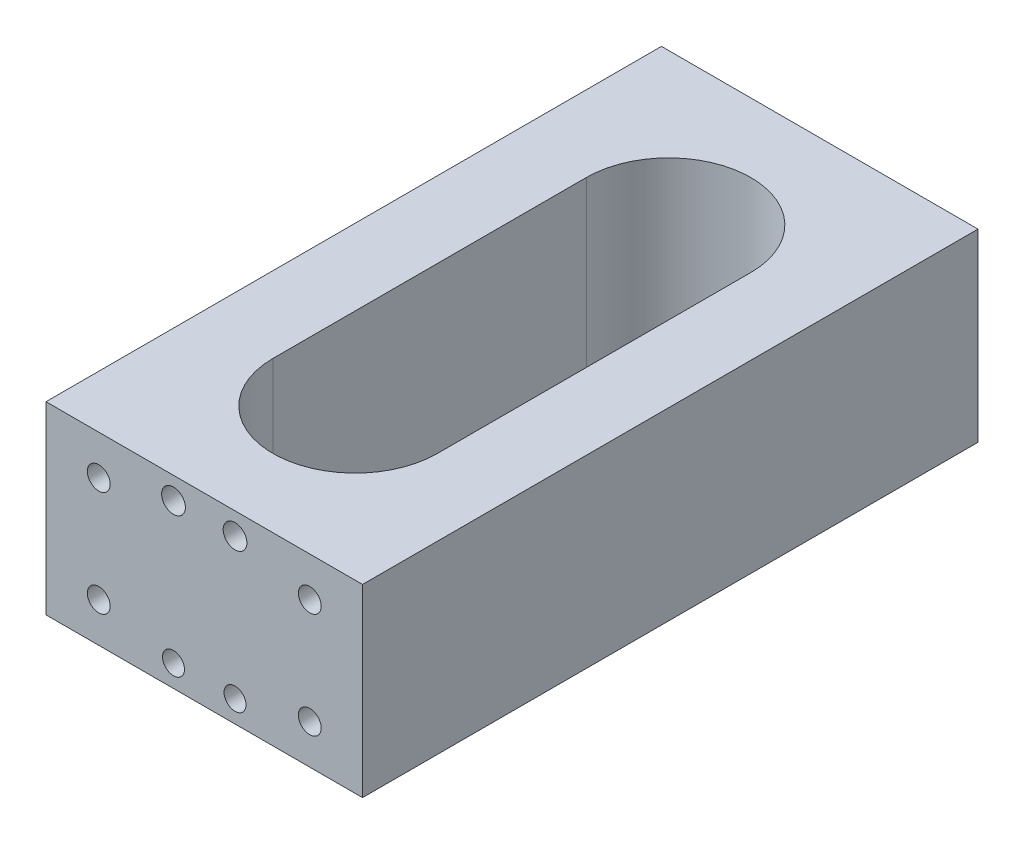
from build123d import *

# Parameters (mm, degrees)
SKETCH_1_W          = 36
SKETCH_1_H          = 21
SKETCH_1_R          = 1.25
SKETCH_1_R_2        = 1.3
SKETCH_1_R_3        = 1.35
EXTRUDE_1_DEPTH     = 70
SKETCH_1_5_R        = 1.3
SKETCH_1_5_R_2      = 1.35
SKETCH_1_5_R_3      = 1.25
CUT_EXTRUDE_1_DEPTH = 4
CUT_EXTRUDE_START   = 70
SKETCH_1_6_R        = 1.35
SKETCH_1_6_R_2      = 1.3
SKETCH_1_6_R_3      = 1.25
CUT_EXTRUDE_2_DEPTH = 4
CUT_EXTRUDE1_DEPTH  = 30


with BuildPart() as part:
    # 스케치1 → 보스-돌출1 (new body)
    with BuildSketch(Plane.XY):
        Rectangle(SKETCH_1_W, SKETCH_1_H)
        with Locations((-3.5, -8)):
            Circle(SKETCH_1_R, mode=Mode.SUBTRACT)
        with Locations((3.5, -8)):
            Circle(SKETCH_1_R, mode=Mode.SUBTRACT)
        with Locations((-12, 6)):
            Circle(SKETCH_1_R_2, mode=Mode.SUBTRACT)
        with Locations((12, 6)):
            Circle(SKETCH_1_R_2, mode=Mode.SUBTRACT)
        with Locations((12, -6)):
            Circle(SKETCH_1_R_2, mode=Mode.SUBTRACT)
        with Locations((-12, -6)):
            Circle(SKETCH_1_R_2, mode=Mode.SUBTRACT)
        with Locations((3.5, 8)):
            Circle(SKETCH_1_R_3, mode=Mode.SUBTRACT)
        with Locations((-3.5, 8)):
            Circle(SKETCH_1_R_3, mode=Mode.SUBTRACT)
        with Locations((12, -6)):
            Circle(SKETCH_1_R_2)
        with Locations((3.5, -8)):
            Circle(SKETCH_1_R)
        with Locations((-3.5, -8)):
            Circle(SKETCH_1_R)
        with Locations((-12, -6)):
            Circle(SKETCH_1_R_2)
        with Locations((-12, 6)):
            Circle(SKETCH_1_R_2)
        with Locations((-3.5, 8)):
            Circle(SKETCH_1_R_3)
        with Locations((3.5, 8)):
            Circle(SKETCH_1_R_3)
        with Locations((12, 6)):
            Circle(SKETCH_1_R_2)
    extrude(amount=EXTRUDE_1_DEPTH)

    # 스케치1<5> → 컷-돌출1 (cut)
    with BuildSketch(Plane.XY):
        with Locations((12, 6)):
            Circle(SKETCH_1_5_R)
        with Locations((3.5, 8)):
            Circle(SKETCH_1_5_R_2)
        with Locations((-3.5, 8)):
            Circle(SKETCH_1_5_R_2)
        with Locations((-12, 6)):
            Circle(SKETCH_1_5_R)
        with Locations((-12, -6)):
            Circle(SKETCH_1_5_R)
        with Locations(Location((-3.5, -8, 0), (0, 0, 180))):
            Circle(SKETCH_1_5_R_3)
        with Locations((3.5, -8)):
            Circle(SKETCH_1_5_R_3)
        with Locations((12, -6)):
            Circle(SKETCH_1_5_R)
    extrude(amount=CUT_EXTRUDE_1_DEPTH, mode=Mode.SUBTRACT)

    # 스케치1<6> → 컷-돌출2 (cut)
    with BuildSketch(Plane.XY.offset(CUT_EXTRUDE_START)):
        with Locations((3.5, 8)):
            Circle(SKETCH_1_6_R)
        with Locations((12, 6)):
            Circle(SKETCH_1_6_R_2)
        with Locations((-3.5, 8)):
            Circle(SKETCH_1_6_R)
        with Locations((-12, 6)):
            Circle(SKETCH_1_6_R_2)
        with Locations((-12, -6)):
            Circle(SKETCH_1_6_R_2)
        with Locations(Location((-3.5, -8, 0), (0, 0, 180))):
            Circle(SKETCH_1_6_R_3)
        with Locations((3.5, -8)):
            Circle(SKETCH_1_6_R_3)
        with Locations((12, -6)):
            Circle(SKETCH_1_6_R_2)
    extrude(amount=-CUT_EXTRUDE_2_DEPTH, mode=Mode.SUBTRACT)

    # Sketch1 → Cut-Extrude1 (cut)
    with BuildSketch(Plane(origin=(0, 10.5, 0), x_dir=(1, 0, 0), z_dir=(0, 1, 0))):
        with BuildLine():
            Line((9.357060489, -17.19326846), (9.357060489, -52.841694339))
            ThreePointArc((9.357060489, -52.841694339), (0, -62.198754828), (-9.357060489, -52.841694339))
            Line((-9.357060489, -52.841694339), (-9.357060489, -17.19326846))
            ThreePointArc((-9.357060489, -17.19326846), (0, -7.836207971), (9.357060489, -17.19326846))
        make_face()
    extrude(amount=-CUT_EXTRUDE1_DEPTH, mode=Mode.SUBTRACT)


solid = part.part
